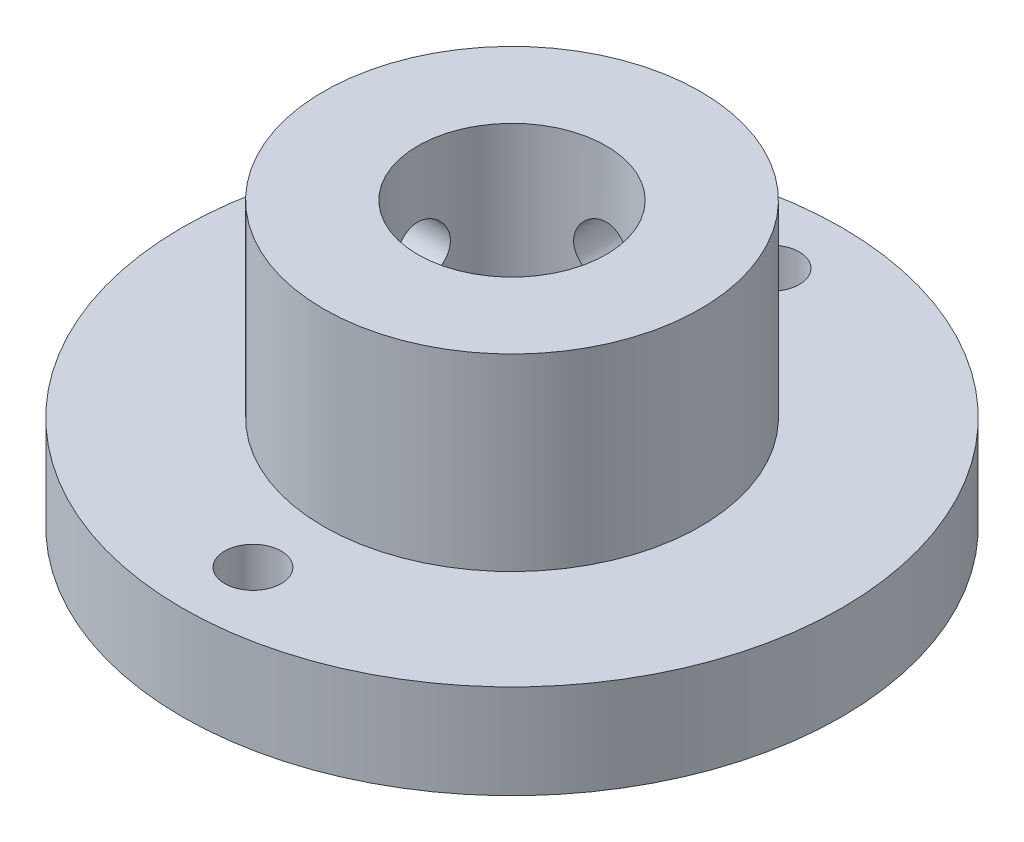
from build123d import *

# Parameters (mm, degrees)
ESBO_O1_R                = 17.5
RESSALTO_EXTRUS_O1_DEPTH = 5
ESBO_O2_R                = 10
RESSALTO_EXTRUS_O2_DEPTH = 10
ESBO_O3_R                = 5
CORTE_EXTRUS_O1_DEPTH    = 16
ESBO_O4_R                = 1.5
CORTE_EXTRUS_O2_DEPTH    = 10
ESBO_O5_R                = 1.5
CORTE_EXTRUS_O3_DEPTH    = 18.5
ESBO_O6_R                = 1.5
CORTE_EXTRUS_O4_DEPTH    = 10


with BuildPart() as part:
    # Esboço1 → Ressalto-extrusão1 (new body)
    with BuildSketch(Plane(origin=(0, 0, 0), x_dir=(1, 0, 0), z_dir=(0, 1, 0))):
        Circle(ESBO_O1_R)
    extrude(amount=RESSALTO_EXTRUS_O1_DEPTH)

    # Esboço2 → Ressalto-extrusão2 (add)
    with BuildSketch(Plane(origin=(0, 5, 0), x_dir=(1, 0, 0), z_dir=(0, 1, 0))):
        Circle(ESBO_O2_R)
    extrude(amount=RESSALTO_EXTRUS_O2_DEPTH)

    # Esboço3 → Corte-extrusão1 (cut, through all)
    with BuildSketch(Plane(origin=(0, 15, 0), x_dir=(1, 0, 0), z_dir=(0, 1, 0))):
        Circle(ESBO_O3_R)
    extrude(amount=-CORTE_EXTRUS_O1_DEPTH, mode=Mode.SUBTRACT)

    # Esboço4 → Corte-extrusão2 (cut)
    with BuildSketch(Plane(origin=(0, 5, 0), x_dir=(1, 0, 0), z_dir=(0, 1, 0))):
        with Locations((0, 13.75)):
            Circle(ESBO_O4_R)
        with Locations((0, -13.75)):
            Circle(ESBO_O4_R)
    extrude(amount=-CORTE_EXTRUS_O2_DEPTH, mode=Mode.SUBTRACT)

    # Esboço5 → Corte-extrusão3 (cut, through all)
    with BuildSketch(Plane.XY):
        with Locations((0, 10)):
            Circle(ESBO_O5_R)
    extrude(amount=-CORTE_EXTRUS_O3_DEPTH, mode=Mode.SUBTRACT)

    # Esboço6 → Corte-extrusão4 (cut)
    with BuildSketch(Plane(origin=(0, 0, 0), x_dir=(0, 0, -1), z_dir=(1, 0, 0))):
        with Locations((0, 10)):
            Circle(ESBO_O6_R)
    extrude(amount=-CORTE_EXTRUS_O4_DEPTH, mode=Mode.SUBTRACT)


solid = part.part
